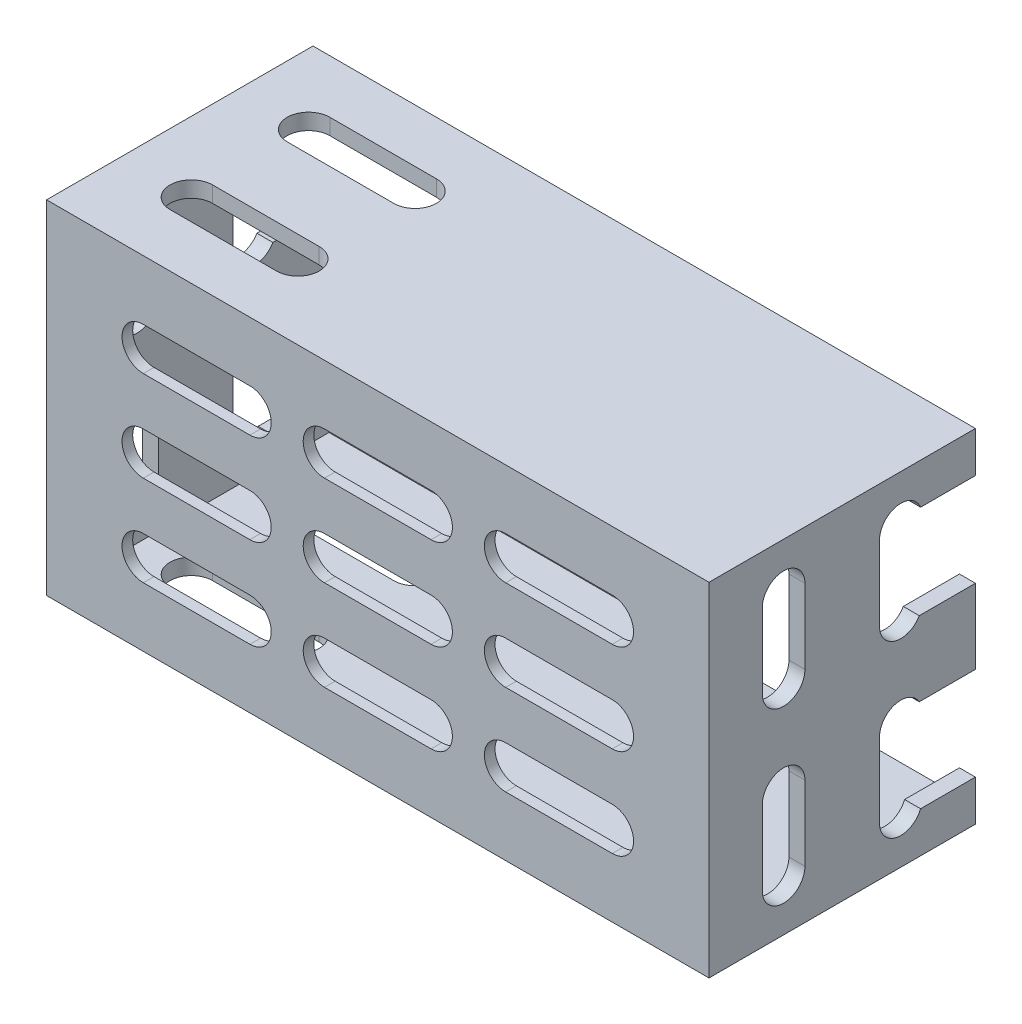
from build123d import *

# Parameters (mm, degrees)
SKETCH1_W           = 62.16
SKETCH1_H           = 32.16
SKETCH1_W_2         = 59.16
SKETCH1_H_2         = 29.16
BOSS_EXTRUDE1_DEPTH = 19
SKETCH2_W           = 62.16
SKETCH2_H           = 32.16
BOSS_EXTRUDE2_DEPTH = 1
BOSS_EXTRUDE3_DEPTH = 5
CUT_EXTRUDE4_DEPTH  = 2
CUT_EXTRUDE2_DEPTH  = 33.16
CUT_EXTRUDE3_DEPTH  = 63.16
SKETCH9_W           = 7
SKETCH9_H           = 8.75
CUT_EXTRUDE5_DEPTH  = 63.16


with BuildPart() as part:
    # Sketch1 → Boss-Extrude1 (new body)
    with BuildSketch(Plane.XY):
        Rectangle(SKETCH1_W, SKETCH1_H)
        Rectangle(SKETCH1_W_2, SKETCH1_H_2, mode=Mode.SUBTRACT)
    extrude(amount=BOSS_EXTRUDE1_DEPTH)

    # Sketch2 → Boss-Extrude2 (add)
    with BuildSketch(Plane.XY.offset(19)):
        Rectangle(SKETCH2_W, SKETCH2_H)
    extrude(amount=BOSS_EXTRUDE2_DEPTH)

    # Sketch3 → Boss-Extrude3 (add)
    with BuildSketch(Plane(origin=(0, 0, 0), x_dir=(-1, 0, 0), z_dir=(0, 0, -1))):
        Polygon((-31.08, -16.08), (31.08, -16.08), (31.08, 16.08), (9, 16.08), (-9, 16.08), (-31.08, 16.08), align=None)
        Polygon((29.58, -14.58), (-29.58, -14.58), (-29.58, 14.58), (-9, 14.58), (9, 14.58), (29.58, 14.58), align=None, mode=Mode.SUBTRACT)
    extrude(amount=BOSS_EXTRUDE3_DEPTH)

    # Sketch8 → Cut-Extrude4 (cut, through all)
    with BuildSketch(Plane(origin=(0, 0, 19), x_dir=(-1, 0, 0), z_dir=(0, 0, -1))):
        with BuildLine():
            Line((12, 6.5), (22, 6.5))
            ThreePointArc((22, 6.5), (24, 8.5), (22, 10.5))
            Line((22, 10.5), (12, 10.5))
            ThreePointArc((12, 10.5), (10, 8.5), (12, 6.5))
        make_face()
        with BuildLine():
            Line((12, -2), (22, -2))
            ThreePointArc((22, -2), (24, 0), (22, 2))
            Line((22, 2), (12, 2))
            ThreePointArc((12, 2), (10, 0), (12, -2))
        make_face()
        with BuildLine():
            Line((12, -10.5), (22, -10.5))
            ThreePointArc((22, -10.5), (24, -8.5), (22, -6.5))
            Line((22, -6.5), (12, -6.5))
            ThreePointArc((12, -6.5), (10, -8.5), (12, -10.5))
        make_face()
        with BuildLine():
            Line((-5, -10.5), (5, -10.5))
            ThreePointArc((5, -10.5), (7, -8.5), (5, -6.5))
            Line((5, -6.5), (-5, -6.5))
            ThreePointArc((-5, -6.5), (-7, -8.5), (-5, -10.5))
        make_face()
        with BuildLine():
            Line((-22, -10.5), (-12, -10.5))
            ThreePointArc((-12, -10.5), (-10, -8.5), (-12, -6.5))
            Line((-12, -6.5), (-22, -6.5))
            ThreePointArc((-22, -6.5), (-24, -8.5), (-22, -10.5))
        make_face()
        with BuildLine():
            Line((-22, -2), (-12, -2))
            ThreePointArc((-12, -2), (-10, 0), (-12, 2))
            Line((-12, 2), (-22, 2))
            ThreePointArc((-22, 2), (-24, 0), (-22, -2))
        make_face()
        with BuildLine():
            Line((-5, 6.5), (5, 6.5))
            ThreePointArc((5, 6.5), (7, 8.5), (5, 10.5))
            Line((5, 10.5), (-5, 10.5))
            ThreePointArc((-5, 10.5), (-7, 8.5), (-5, 6.5))
        make_face()
        with BuildLine():
            Line((-22, 6.5), (-12, 6.5))
            ThreePointArc((-12, 6.5), (-10, 8.5), (-12, 10.5))
            Line((-12, 10.5), (-22, 10.5))
            ThreePointArc((-22, 10.5), (-24, 8.5), (-22, 6.5))
        make_face()
        with BuildLine():
            Line((-5, -2), (5, -2))
            ThreePointArc((5, -2), (7, 0), (5, 2))
            Line((5, 2), (-5, 2))
            ThreePointArc((-5, 2), (-7, 0), (-5, -2))
        make_face()
    extrude(amount=-CUT_EXTRUDE4_DEPTH, mode=Mode.SUBTRACT)

    # Sketch5 → Cut-Extrude2 (cut, through all)
    with BuildSketch(Plane(origin=(-15, 16.08, 0), x_dir=(1, 0, 0), z_dir=(0, -1, 0))):
        with BuildLine():
            Line((-9.5, 4), (0.5, 4))
            ThreePointArc((0.5, 4), (2.5, 2), (0.5, 0))
            Line((0.5, 0), (-9.5, 0))
            ThreePointArc((-9.5, 0), (-11.5, 2), (-9.5, 4))
        make_face()
        with BuildLine():
            Line((10, -32.734958022), (20, -32.734958022))
            ThreePointArc((20, -32.734958022), (22, -30.734958022), (20, -28.734958022))
            Line((20, -28.734958022), (10, -28.734958022))
            ThreePointArc((10, -28.734958022), (8, -30.734958022), (10, -32.734958022))
        make_face()
        with BuildLine():
            Line((29.5, -65.469916045), (39.5, -65.469916045))
            ThreePointArc((39.5, -65.469916045), (41.5, -63.469916045), (39.5, -61.469916045))
            Line((39.5, -61.469916045), (29.5, -61.469916045))
            ThreePointArc((29.5, -61.469916045), (27.5, -63.469916045), (29.5, -65.469916045))
        make_face()
        with BuildLine():
            Line((10, -21.734958022), (20, -21.734958022))
            ThreePointArc((20, -21.734958022), (22, -19.734958022), (20, -17.734958022))
            Line((20, -17.734958022), (10, -17.734958022))
            ThreePointArc((10, -17.734958022), (8, -19.734958022), (10, -21.734958022))
        make_face()
        with BuildLine():
            Line((29.5, -54.469916045), (39.5, -54.469916045))
            ThreePointArc((39.5, -54.469916045), (41.5, -52.469916045), (39.5, -50.469916045))
            Line((39.5, -50.469916045), (29.5, -50.469916045))
            ThreePointArc((29.5, -50.469916045), (27.5, -52.469916045), (29.5, -54.469916045))
        make_face()
        with BuildLine():
            Line((-9.5, 11), (0.5, 11))
            ThreePointArc((0.5, 11), (2.5, 13), (0.5, 15))
            Line((0.5, 15), (-9.5, 15))
            ThreePointArc((-9.5, 15), (-11.5, 13), (-9.5, 11))
        make_face()
    extrude(amount=CUT_EXTRUDE2_DEPTH, mode=Mode.SUBTRACT)

    # Sketch7 → Cut-Extrude3 (cut, through all)
    with BuildSketch(Plane(origin=(31.08, -15, 0), x_dir=(0, 0, -1), z_dir=(-1, 0, 0))):
        with BuildLine():
            Line((-15, -26.5), (-15, -19.5))
            ThreePointArc((-15, -19.5), (-13, -17.5), (-11, -19.5))
            Line((-11, -19.5), (-11, -26.5))
            ThreePointArc((-11, -26.5), (-13, -28.5), (-15, -26.5))
        make_face()
        with BuildLine():
            Line((0, -26.5), (0, -19.5))
            ThreePointArc((0, -19.5), (-2, -17.5), (-4, -19.5))
            Line((-4, -19.5), (-4, -26.5))
            ThreePointArc((-4, -26.5), (-2, -28.5), (0, -26.5))
        make_face()
        with BuildLine():
            Line((0, -10.5), (0, -3.5))
            ThreePointArc((0, -3.5), (-2, -1.5), (-4, -3.5))
            Line((-4, -3.5), (-4, -10.5))
            ThreePointArc((-4, -10.5), (-2, -12.5), (0, -10.5))
        make_face()
        with BuildLine():
            Line((-11, -10.5), (-11, -3.5))
            ThreePointArc((-11, -3.5), (-13, -1.5), (-15, -3.5))
            Line((-15, -3.5), (-15, -10.5))
            ThreePointArc((-15, -10.5), (-13, -12.5), (-11, -10.5))
        make_face()
    extrude(amount=CUT_EXTRUDE3_DEPTH, mode=Mode.SUBTRACT)

    # Sketch9 → Cut-Extrude5 (cut, through all)
    with BuildSketch(Plane.ZY.offset(31.08)):
        with Locations((-1.5, 7.875)):
            Rectangle(SKETCH9_W, SKETCH9_H)
        with Locations((-1.5, -7.875)):
            Rectangle(SKETCH9_W, SKETCH9_H)
    extrude(amount=-CUT_EXTRUDE5_DEPTH, mode=Mode.SUBTRACT)


solid = part.part
